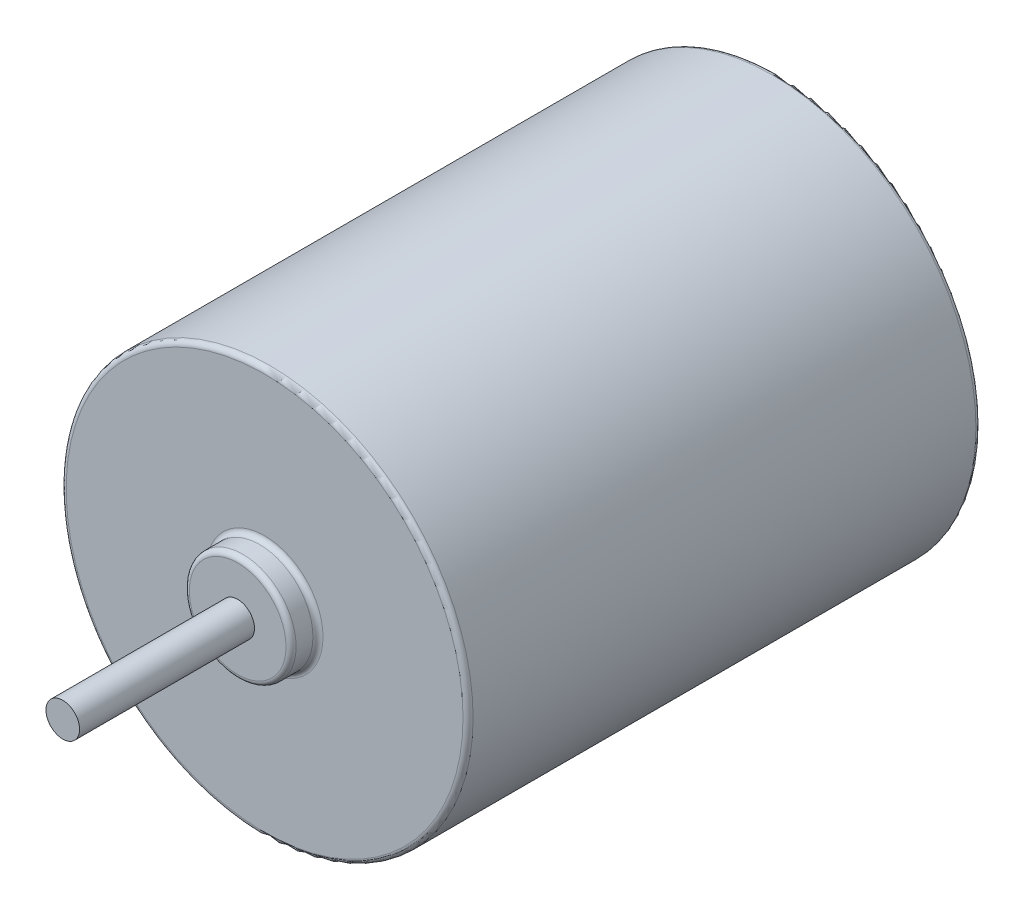
from build123d import *

# Parameters (mm, degrees)
SKETCH1_R           = 12.1
BOSS_EXTRUDE1_DEPTH = 30.5
SKETCH3_R           = 3.175
BOSS_EXTRUDE2_DEPTH = 1.6
SKETCH4_R           = 1
BOSS_EXTRUDE3_DEPTH = 10.4
SKETCH5_R           = 4.25
BOSS_EXTRUDE4_DEPTH = 2
FILLET1_R           = 0.3
FILLET2_R           = 0.3


with BuildPart() as part:
    # Sketch1 → Boss-Extrude1 (new body)
    with BuildSketch(Plane.XY):
        Circle(SKETCH1_R)
    extrude(amount=-BOSS_EXTRUDE1_DEPTH)

    # Sketch3 → Boss-Extrude2 (add)
    with BuildSketch(Plane.XY):
        Circle(SKETCH3_R)
    extrude(amount=BOSS_EXTRUDE2_DEPTH)

    # Sketch4 → Boss-Extrude3 (add)
    with BuildSketch(Plane.XY.offset(1.6)):
        Circle(SKETCH4_R)
    extrude(amount=BOSS_EXTRUDE3_DEPTH)

    # Sketch5 → Boss-Extrude4 (add)
    with BuildSketch(Plane(origin=(0, 0, -30.5), x_dir=(-1, 0, 0), z_dir=(0, 0, -1))):
        Circle(SKETCH5_R)
    extrude(amount=BOSS_EXTRUDE4_DEPTH)

    # Fillet1
    fillet1_edges = [part.edges().sort_by_distance(p)[0] for p in [
        (-3.175, 0, 0),
    ]]
    fillet(fillet1_edges, radius=FILLET1_R)

    # Fillet2
    fillet2_edges = [part.edges().sort_by_distance(p)[0] for p in [
        (4.25, 0, -30.5),
        (4.25, 0, -32.5),
        (-12.1, 0, 0),
        (-12.1, 0, -30.5),
        (-3.175, 0, 1.6),
    ]]
    fillet(fillet2_edges, radius=FILLET2_R)


solid = part.part
